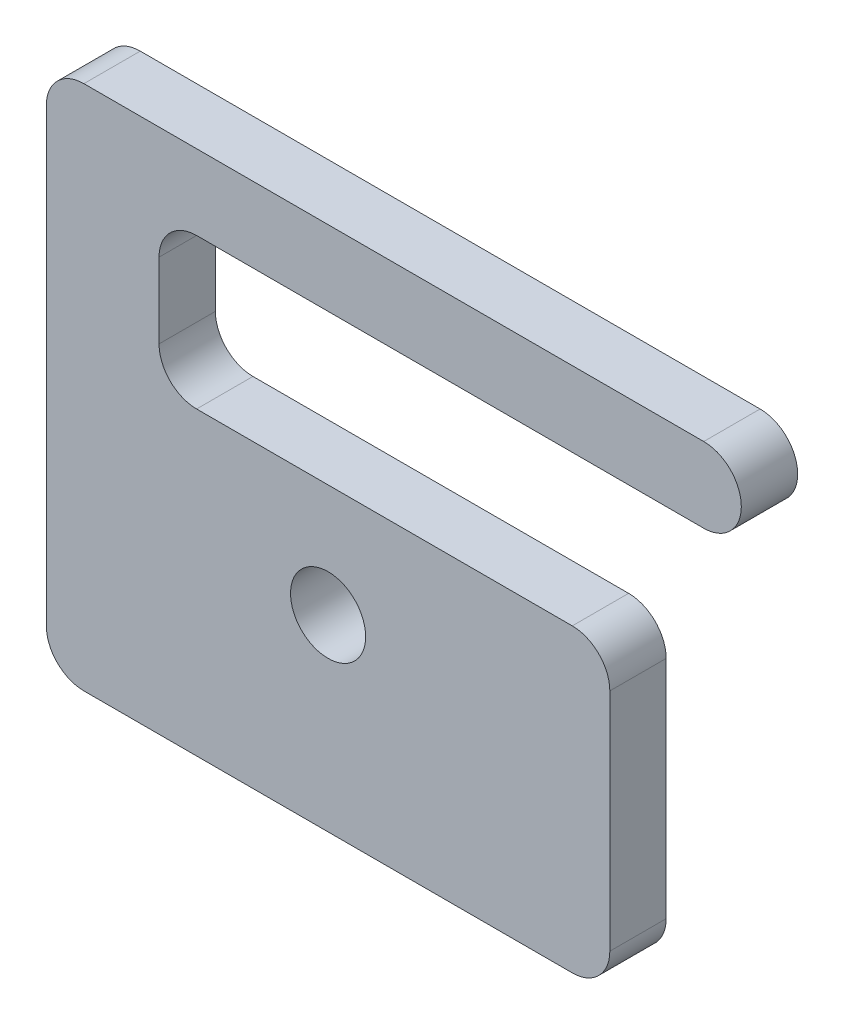
from build123d import *

# Parameters (mm, degrees)
ESQUISSE1_R        = 0.1
BOSS_EXTRU_1_DEPTH = 0.15


with BuildPart() as part:
    # Esquisse1 → Boss.-Extru.1 (new body)
    with BuildSketch(Plane.XY):
        with BuildLine():
            Line((0.75, 0.2), (0.75, -0.4))
            ThreePointArc((0.75, -0.4), (0.720710678, -0.470710678), (0.65, -0.5))
            Line((0.65, -0.5), (-0.65, -0.5))
            ThreePointArc((-0.65, -0.5), (-0.720710678, -0.470710678), (-0.75, -0.4))
            Line((-0.75, -0.4), (-0.75, 0.8))
            ThreePointArc((-0.75, 0.8), (-0.720710678, 0.870710678), (-0.65, 0.9))
            Line((-0.65, 0.9), (1, 0.9))
            ThreePointArc((1, 0.9), (1.1, 0.8), (1, 0.7))
            Line((1, 0.7), (-0.35, 0.7))
            ThreePointArc((-0.35, 0.7), (-0.420710678, 0.670710678), (-0.45, 0.6))
            Line((-0.45, 0.6), (-0.45, 0.4))
            ThreePointArc((-0.45, 0.4), (-0.420710678, 0.329289322), (-0.35, 0.3))
            Line((-0.35, 0.3), (0.65, 0.3))
            ThreePointArc((0.65, 0.3), (0.720710678, 0.270710678), (0.75, 0.2))
        make_face()
        Circle(ESQUISSE1_R, mode=Mode.SUBTRACT)
    extrude(amount=-BOSS_EXTRU_1_DEPTH)


solid = part.part
